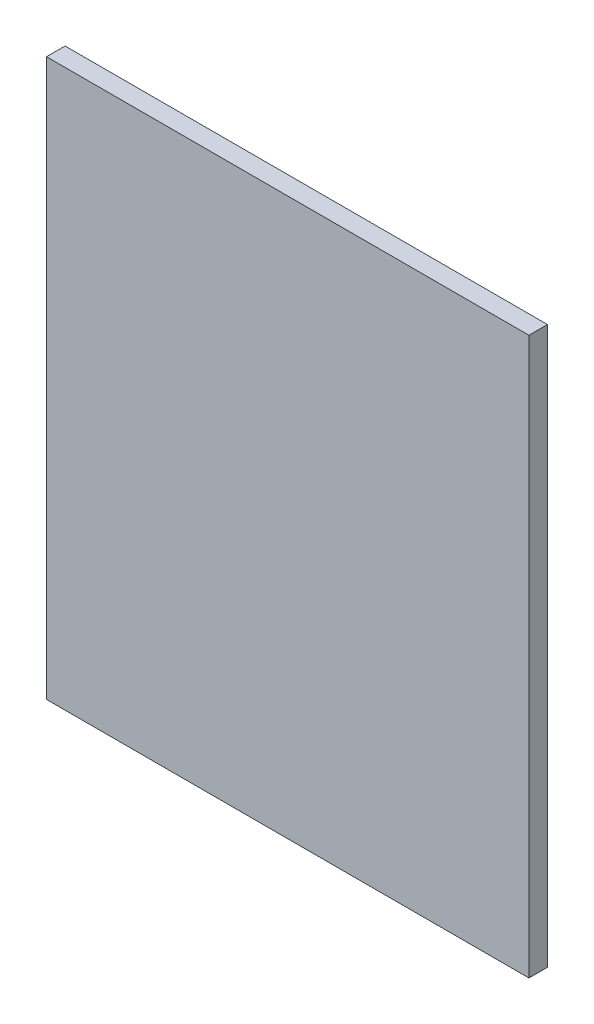
from build123d import *

# Parameters (mm, degrees)
ESBO_O1_W                = 52
ESBO_O1_H                = 60
RESSALTO_EXTRUS_O1_DEPTH = 2


with BuildPart() as part:
    # Esboço1 → Ressalto-extrusão1 (new body)
    with BuildSketch(Plane.XY):
        with Locations((26, 30)):
            Rectangle(ESBO_O1_W, ESBO_O1_H)
    extrude(amount=RESSALTO_EXTRUS_O1_DEPTH)


solid = part.part
